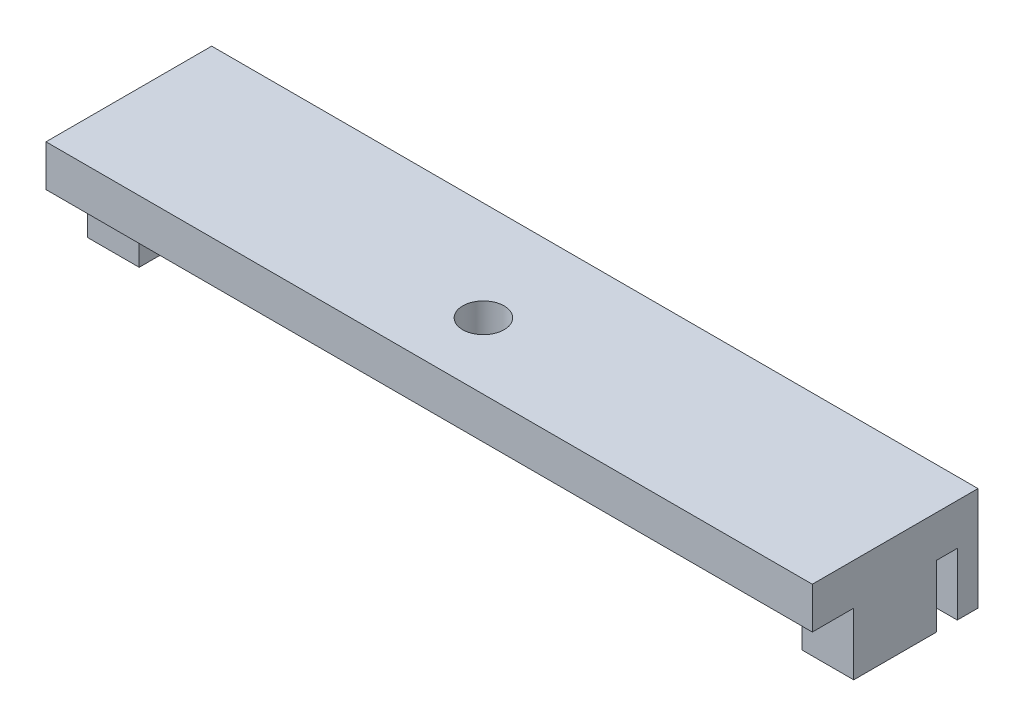
from build123d import *

# Parameters (mm, degrees)
SKETCH1_W           = 37
SKETCH1_H           = 8
BOSS_EXTRUDE1_DEPTH = 2
SKETCH2_R           = 1
CUT_EXTRUDE1_DEPTH  = 3
SKETCH3_W           = 2.5
SKETCH3_H           = 4
SKETCH3_H_2         = 1
BOSS_EXTRUDE2_DEPTH = 3


with BuildPart() as part:
    # Sketch1 → Boss-Extrude1 (new body)
    with BuildSketch(Plane(origin=(0, 0, 0), x_dir=(1, 0, 0), z_dir=(0, 1, 0))):
        Rectangle(SKETCH1_W, SKETCH1_H)
    extrude(amount=BOSS_EXTRUDE1_DEPTH)

    # Sketch2 → Cut-Extrude1 (cut, through all)
    with BuildSketch(Plane(origin=(0, 2, 0), x_dir=(1, 0, 0), z_dir=(0, 1, 0))):
        with Locations((-0.58, -0.8)):
            Circle(SKETCH2_R)
    extrude(amount=-CUT_EXTRUDE1_DEPTH, mode=Mode.SUBTRACT)

    # Sketch3 → Boss-Extrude2 (add)
    with BuildSketch(Plane.XZ):
        with Locations((17.25, 0)):
            Rectangle(SKETCH3_W, SKETCH3_H)
        with Locations((17.25, -3.5)):
            Rectangle(SKETCH3_W, SKETCH3_H_2)
        with Locations((-17.25, -3.5)):
            Rectangle(SKETCH3_W, SKETCH3_H_2)
        with Locations((-17.25, 0)):
            Rectangle(SKETCH3_W, SKETCH3_H)
    extrude(amount=BOSS_EXTRUDE2_DEPTH)


solid = part.part
